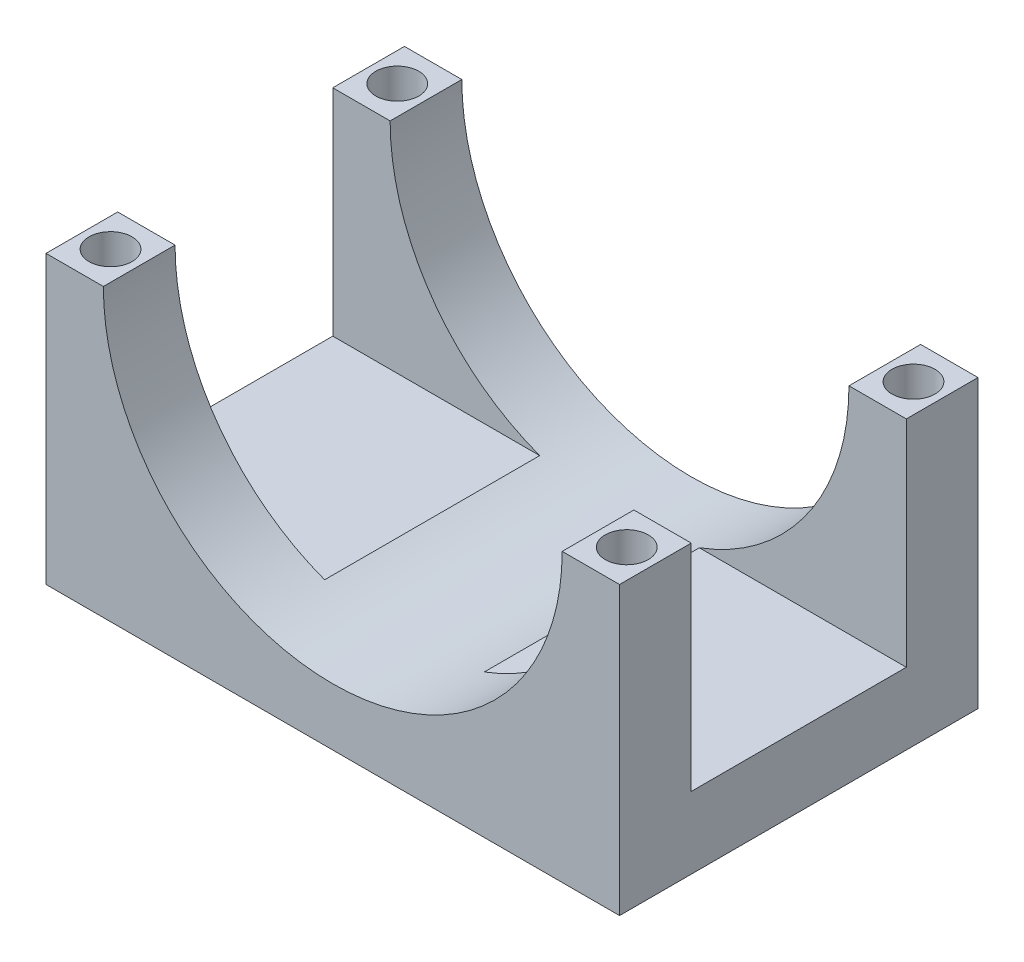
from build123d import *

# Parameters (mm, degrees)
CROQUIS1_W              = 40
CROQUIS1_H              = 25
SALIENTE_EXTRUIR1_DEPTH = 20
CROQUIS2_R              = 16
CORTAR_EXTRUIR1_DEPTH   = 26
CROQUIS3_R              = 1.5
CORTAR_EXTRUIR2_DEPTH   = 21
CROQUIS4_W              = 15
CROQUIS4_H              = 15
CORTAR_EXTRUIR3_DEPTH   = 41


with BuildPart() as part:
    # Croquis1 → Saliente-Extruir1 (new body)
    with BuildSketch(Plane(origin=(0, 0, 0), x_dir=(1, 0, 0), z_dir=(0, 1, 0))):
        with Locations((20, 12.5)):
            Rectangle(CROQUIS1_W, CROQUIS1_H)
    extrude(amount=SALIENTE_EXTRUIR1_DEPTH)

    # Croquis2 → Cortar-Extruir1 (cut, through all)
    with BuildSketch(Plane.XY):
        with Locations((20, 20)):
            Circle(CROQUIS2_R)
    extrude(amount=-CORTAR_EXTRUIR1_DEPTH, mode=Mode.SUBTRACT)

    # Croquis3 → Cortar-Extruir2 (cut, through all)
    with BuildSketch(Plane(origin=(0, 20, 0), x_dir=(1, 0, 0), z_dir=(0, 1, 0))):
        with Locations((2, 2.5)):
            Circle(CROQUIS3_R)
        with Locations((2, 22.5)):
            Circle(CROQUIS3_R)
        with Locations((38, 2.5)):
            Circle(CROQUIS3_R)
        with Locations((38, 22.5)):
            Circle(CROQUIS3_R)
    extrude(amount=-CORTAR_EXTRUIR2_DEPTH, mode=Mode.SUBTRACT)

    # Croquis4 → Cortar-Extruir3 (cut, through all)
    with BuildSketch(Plane(origin=(40, 0, 0), x_dir=(0, 0, -1), z_dir=(1, 0, 0))):
        with Locations((12.5, 12.5)):
            Rectangle(CROQUIS4_W, CROQUIS4_H)
    extrude(amount=-CORTAR_EXTRUIR3_DEPTH, mode=Mode.SUBTRACT)


solid = part.part
